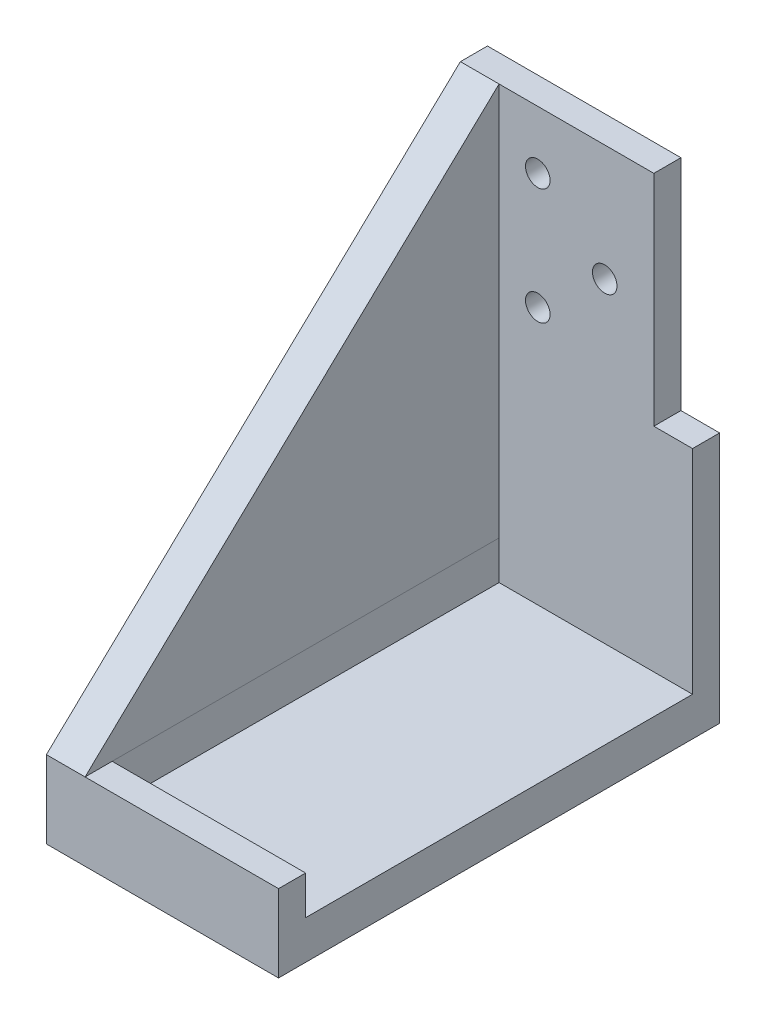
from build123d import *

# Parameters (mm, degrees)
SKETCH1_W           = 60
SKETCH1_H           = 114
BOSS_EXTRUDE1_DEPTH = 10
SKETCH3_W           = 60
SKETCH3_H           = 7
BOSS_EXTRUDE2_DEPTH = 111.6
BOSS_EXTRUDE5_DEPTH = 10
BOSS_EXTRUDE3_DEPTH = 10
SKETCH7_W           = 10
SKETCH7_H           = 7
CUT_EXTRUDE1_DEPTH  = 56.6
SKETCH8_R           = 3.175
CUT_EXTRUDE2_DEPTH  = 8


with BuildPart() as part:
    # Sketch1 → Boss-Extrude1 (new body)
    with BuildSketch(Plane(origin=(0, 0, 0), x_dir=(1, 0, 0), z_dir=(0, 1, 0))):
        Rectangle(SKETCH1_W, SKETCH1_H)
    extrude(amount=-BOSS_EXTRUDE1_DEPTH)

    # Sketch3 → Boss-Extrude2 (add)
    with BuildSketch(Plane(origin=(0, 0, 0), x_dir=(1, 0, 0), z_dir=(0, 1, 0))):
        with Locations((0, 53.5)):
            Rectangle(SKETCH3_W, SKETCH3_H)
    extrude(amount=BOSS_EXTRUDE2_DEPTH)

    # Sketch6 → Boss-Extrude5 (add)
    with BuildSketch(Plane(origin=(0, 0, 0), x_dir=(1, 0, 0), z_dir=(0, 1, 0))):
        Polygon((-30, 50), (-20, 50), (-20.103587149, -50), (30, -50), (30, -57), (-30, -57), align=None)
    extrude(amount=BOSS_EXTRUDE5_DEPTH)

    # Sketch4 → Boss-Extrude3 (add)
    with BuildSketch(Plane.ZY.offset(30)):
        Polygon((-57, 10), (57, 10), (-50, 111.6), (-57, 111.6), align=None)
    extrude(amount=-BOSS_EXTRUDE3_DEPTH)

    # Sketch7 → Cut-Extrude1 (cut)
    with BuildSketch(Plane(origin=(0, 111.6, 0), x_dir=(1, 0, 0), z_dir=(0, 1, 0))):
        with Locations((25, 53.5)):
            Rectangle(SKETCH7_W, SKETCH7_H)
    extrude(amount=-CUT_EXTRUDE1_DEPTH, mode=Mode.SUBTRACT)

    # Sketch8 → Cut-Extrude2 (cut, through all)
    with BuildSketch(Plane.XY.offset(-50)):
        with Locations((-10, 96.6)):
            Circle(SKETCH8_R)
        with Locations((7.3, 81.6)):
            Circle(SKETCH8_R)
        with Locations((-10, 66.6)):
            Circle(SKETCH8_R)
    extrude(amount=-CUT_EXTRUDE2_DEPTH, mode=Mode.SUBTRACT)


solid = part.part
